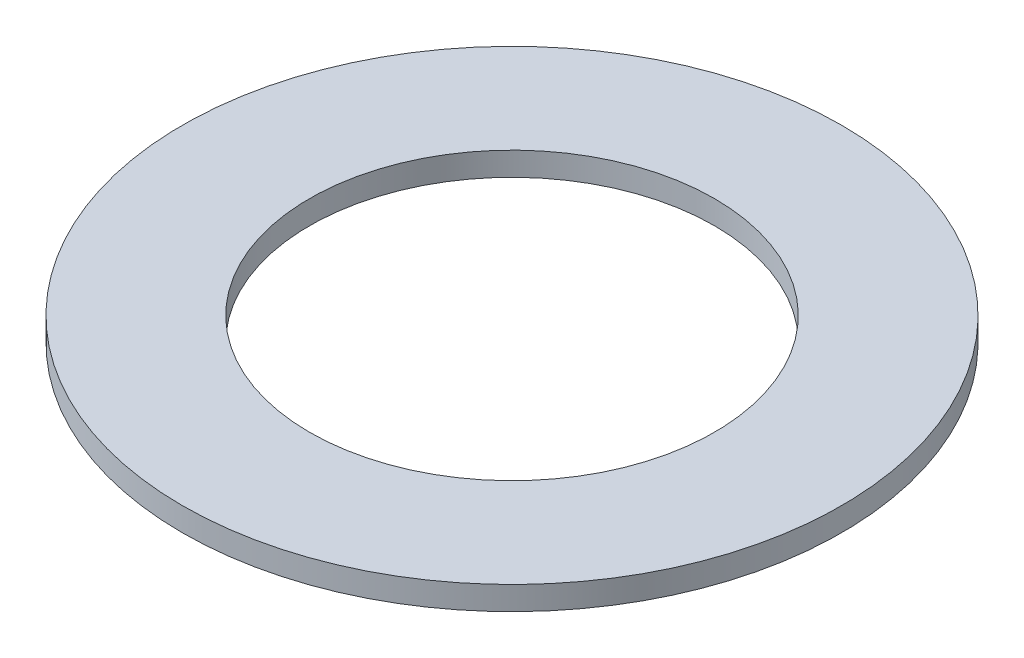
from build123d import *

# Parameters (mm, degrees)
SKETCH1_R           = 7
SKETCH1_R_2         = 4.3
BOSS_EXTRUDE1_DEPTH = 0.5


with BuildPart() as part:
    # Sketch1 → Boss-Extrude1 (new body)
    with BuildSketch(Plane(origin=(0, 0, 0), x_dir=(1, 0, 0), z_dir=(0, 1, 0))):
        Circle(SKETCH1_R)
        Circle(SKETCH1_R_2, mode=Mode.SUBTRACT)
    extrude(amount=BOSS_EXTRUDE1_DEPTH)


solid = part.part
